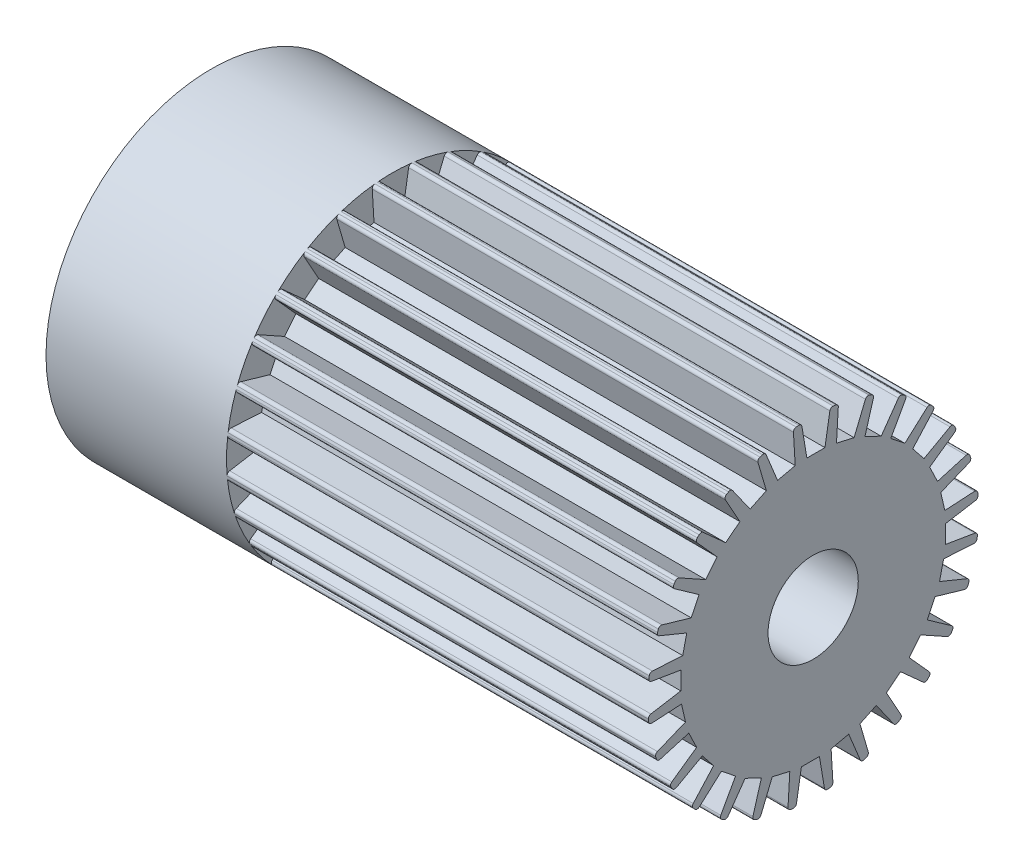
from build123d import *

# Parameters (mm, degrees)
SKETCH2_W                = 10
SKETCH2_H                = 2
CUT_EXTRUDE1_DEPTH       = 7
FILLET1_R                = 0.05
CIRPATTERN6_COUNT        = 28
FILLET1_OF_CIRPATTERN6_R = 0.05


with BuildPart() as part:
    # Sketch2 → Revolve2 (revolve)
    with BuildSketch(Plane.XY):
        with Locations((-0.575271603, 1.75)):
            Rectangle(SKETCH2_W, SKETCH2_H)
    revolve(axis=Axis((0, 0, 0), (-1, 0, 0)))

    # Sketch3 → Cut-Extrude1 (cut)
    with BuildSketch(Plane(origin=(4.424728397, 0, 0), x_dir=(0, 0, -1), z_dir=(1, 0, 0))):
        Polygon((-0.204125548, 2.799617343), (-0.104125548, 2.199617343), (0.195874452, 2.199617343), (0.295874452, 2.799617343), align=None)
    cut_extrude1 = extrude(amount=-CUT_EXTRUDE1_DEPTH, mode=Mode.SUBTRACT)

    # Fillet1
    fillet1_edges = [part.edges().sort_by_distance(p)[0] for p in [
        (0.924728397, 2.743098553, 0.194705749),
        (0.924728397, 2.735177926, -0.28513455),
    ]]
    fillet(fillet1_edges, radius=FILLET1_R)

    # CirPattern6: Cut-Extrude1 ×28 about axis
    cirpattern6_axis = Axis((0, 0, 0), (1, 0, 0))
    for i in range(1, CIRPATTERN6_COUNT):
        add(cut_extrude1.rotate(cirpattern6_axis, i * 360 / CIRPATTERN6_COUNT), mode=Mode.SUBTRACT)

    # Fillet1 of CirPattern6
    fillet1_of_cirpattern6_edges = [part.edges().sort_by_distance(p)[0] for p in [
        (0.924728397, 2.63099724, 0.800220922),
        (0.924728397, 2.730049711, 0.330648716),
        (0.924728397, 2.386966739, 1.365609675),
        (0.924728397, 2.588025404, 0.929851874),
        (0.924728397, 2.023243759, 1.862521058),
        (0.924728397, 2.316226697, 1.482428376),
        (0.924728397, 1.558066889, 2.266037857),
        (0.924728397, 1.928282711, 1.960669729),
        (0.924728397, 1.014762038, 2.555926056),
        (0.924728397, 1.443646578, 2.340594915),
        (0.924728397, 0.420572782, 2.71764945),
        (0.924728397, 0.886619978, 2.603152899),
        (0.924728397, -0.194705749, 2.743098553),
        (0.924728397, 0.28513455, 2.735177926),
        (0.924728397, -0.800220922, 2.63099724),
        (0.924728397, -0.330648716, 2.730049711),
        (0.924728397, -1.365609675, 2.386966739),
        (0.924728397, -0.929851874, 2.588025404),
        (0.924728397, -1.862521058, 2.023243759),
        (0.924728397, -1.482428376, 2.316226697),
        (0.924728397, -2.266037857, 1.558066889),
        (0.924728397, -1.960669729, 1.928282711),
        (0.924728397, -2.555926056, 1.014762038),
        (0.924728397, -2.340594915, 1.443646578),
        (0.924728397, -2.71764945, 0.420572782),
        (0.924728397, -2.603152899, 0.886619978),
        (0.924728397, -2.743098553, -0.194705749),
        (0.924728397, -2.735177926, 0.28513455),
        (0.924728397, -2.63099724, -0.800220922),
        (0.924728397, -2.730049711, -0.330648716),
        (0.924728397, -2.386966739, -1.365609675),
        (0.924728397, -2.588025404, -0.929851874),
        (0.924728397, -2.023243759, -1.862521058),
        (0.924728397, -2.316226697, -1.482428376),
        (0.924728397, -1.558066889, -2.266037857),
        (0.924728397, -1.928282711, -1.960669729),
        (0.924728397, -1.014762038, -2.555926056),
        (0.924728397, -1.443646578, -2.340594915),
        (0.924728397, -0.420572782, -2.71764945),
        (0.924728397, -0.886619978, -2.603152899),
        (0.924728397, 0.194705749, -2.743098553),
        (0.924728397, -0.28513455, -2.735177926),
        (0.924728397, 0.800220922, -2.63099724),
        (0.924728397, 0.330648716, -2.730049711),
        (0.924728397, 1.365609675, -2.386966739),
        (0.924728397, 0.929851874, -2.588025404),
        (0.924728397, 1.862521058, -2.023243759),
        (0.924728397, 1.482428376, -2.316226697),
        (0.924728397, 2.266037857, -1.558066889),
        (0.924728397, 1.960669729, -1.928282711),
        (0.924728397, 2.555926056, -1.014762038),
        (0.924728397, 2.340594915, -1.443646578),
        (0.924728397, 2.71764945, -0.420572782),
        (0.924728397, 2.603152899, -0.886619978),
    ]]
    fillet(fillet1_of_cirpattern6_edges, radius=FILLET1_OF_CIRPATTERN6_R)


solid = part.part
